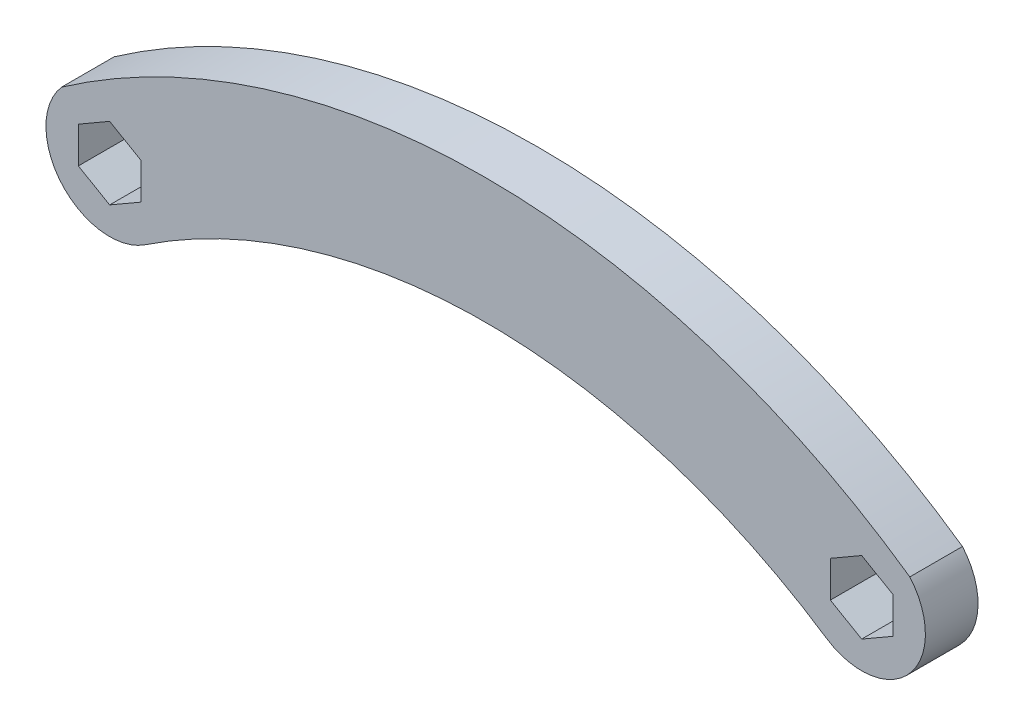
from build123d import *

# Parameters (mm, degrees)
BOSS_EXTRUDE1_DEPTH = 5.334


with BuildPart() as part:
    # Sketch1 → Boss-Extrude1 (new body)
    with BuildSketch(Plane.XY):
        with BuildLine():
            ThreePointArc((42.977057526, 61.379780274), (0, 74.93), (-42.977057526, 61.379780274))
            ThreePointArc((-42.977057526, 61.379780274), (-42.944185328, 52.882612065), (-34.518993211, 51.778489817))
            ThreePointArc((-34.518993211, 51.778489817), (0, 62.23), (34.518993211, 51.778489817))
            ThreePointArc((34.518993211, 51.778489817), (42.944185328, 52.882612065), (42.977057526, 61.379780274))
        make_face()
        Polygon((-38.1, 60.816174209), (-41.275, 58.983087105), (-41.275, 55.316912895), (-38.1, 53.483825791), (-34.925, 55.316912895), (-34.925, 58.983087105), align=None, mode=Mode.SUBTRACT)
        Polygon((38.1, 60.816174209), (34.925, 58.983087105), (34.925, 55.316912895), (38.1, 53.483825791), (41.275, 55.316912895), (41.275, 58.983087105), align=None, mode=Mode.SUBTRACT)
    extrude(amount=BOSS_EXTRUDE1_DEPTH)


solid = part.part
